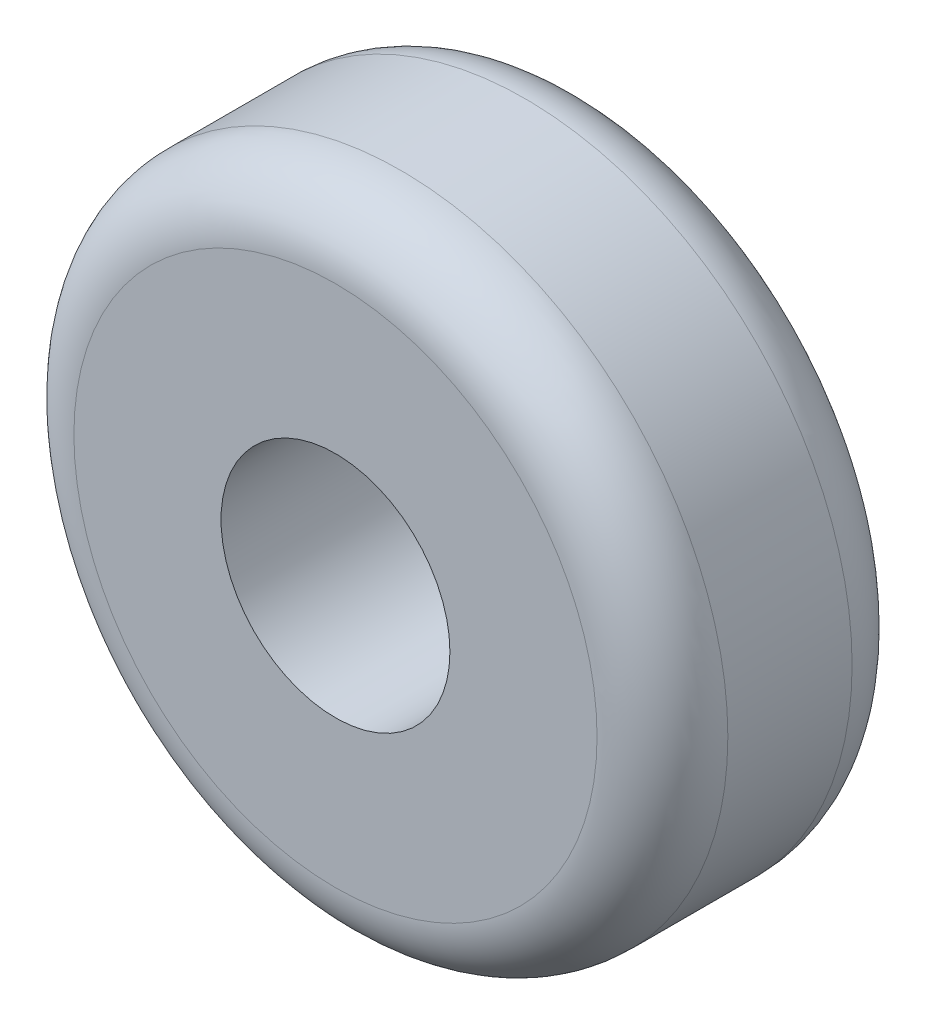
from build123d import *

# Parameters (mm, degrees)
ESQUISSE1_R        = 50
ESQUISSE1_R_2      = 17.5
BOSS_EXTRU_1_DEPTH = 39
CONG_1_R           = 10


with BuildPart() as part:
    # Esquisse1 → Boss.-Extru.1 (new body)
    with BuildSketch(Plane.XY):
        Circle(ESQUISSE1_R)
        Circle(ESQUISSE1_R_2, mode=Mode.SUBTRACT)
    extrude(amount=BOSS_EXTRU_1_DEPTH)

    # Congé1
    cong_1_edges = [part.edges().sort_by_distance(p)[0] for p in [
        (-50, 0, 39),
        (-50, 0, 0),
    ]]
    fillet(cong_1_edges, radius=CONG_1_R)


solid = part.part
